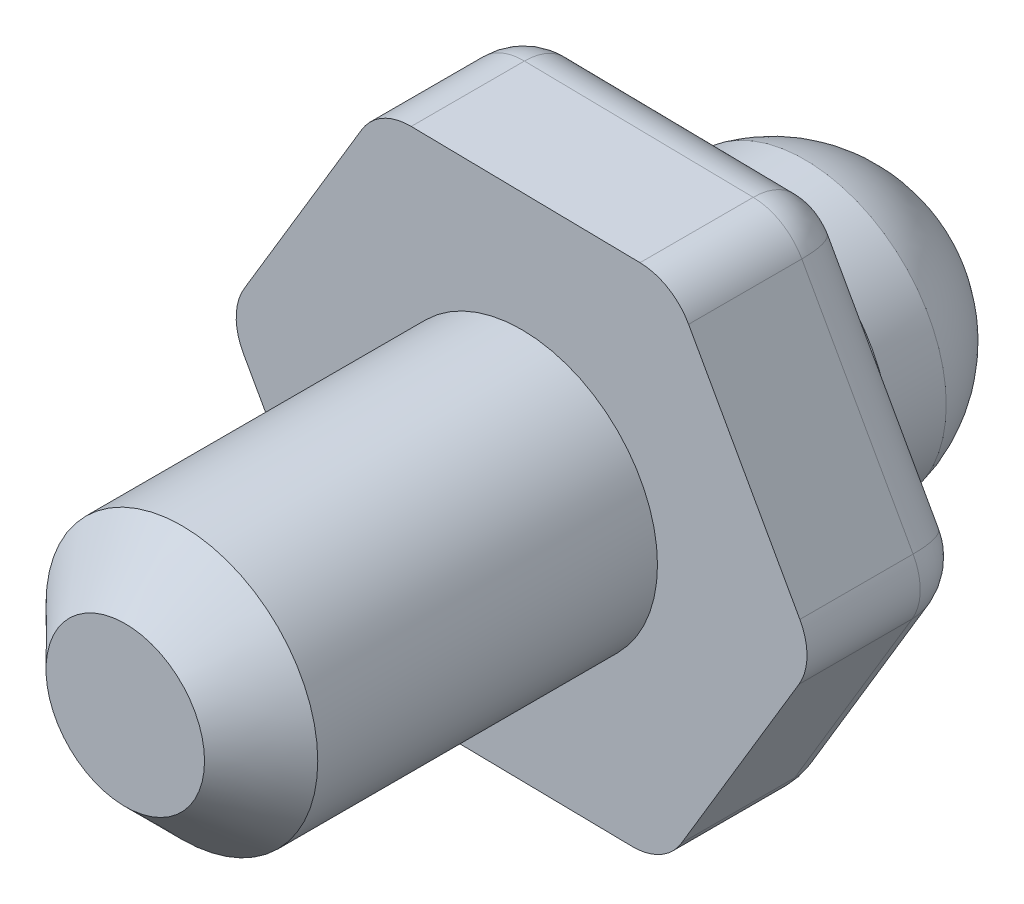
from build123d import *

# Parameters (mm, degrees)
SKETCH1_R         = 3.048
EXTRUDE1_DEPTH    = 8.89
CHAMFER1_SIZE     = 1.27
EXTRUDE2_DEPTH    = 3.81
SKETCH3_R         = 2.029785207
EXTRUDE3_DEPTH    = 1.27
SKETCH4_R         = 3.175
EXTRUDE4_DEPTH    = 1.27
DOME1_FACE_RADIUS = 3.175
DOME1_HEIGHT      = 2.54
FILLET1_R         = 1.27


with BuildPart() as part:
    # Sketch1 → Extrude1 (new body)
    with BuildSketch(Plane.XY):
        Circle(SKETCH1_R)
    extrude(amount=EXTRUDE1_DEPTH)

    # Chamfer1
    chamfer1_edges = [part.edges().sort_by_distance(p)[0] for p in [
        (-3.048, 0, 8.89),
    ]]
    chamfer(chamfer1_edges, length=CHAMFER1_SIZE)

    # Sketch2 → Extrude2 (add)
    with BuildSketch(Plane(origin=(0, 0, 0), x_dir=(-1, 0, 0), z_dir=(0, 0, -1))):
        Polygon((6.598292207, 0.104115064), (3.208979813, 5.766346205), (-3.389312394, 5.662231141), (-6.598292207, -0.104115064), (-3.208979813, -5.766346205), (3.389312394, -5.662231141), align=None)
    extrude(amount=EXTRUDE2_DEPTH)

    # Sketch3 → Extrude3 (add)
    with BuildSketch(Plane(origin=(0, 0, -3.81), x_dir=(-1, 0, 0), z_dir=(0, 0, -1))):
        Circle(SKETCH3_R)
    extrude(amount=EXTRUDE3_DEPTH)

    # Sketch4 → Extrude4 (add)
    with BuildSketch(Plane(origin=(0, 0, -5.08), x_dir=(-1, 0, 0), z_dir=(0, 0, -1))):
        Circle(SKETCH4_R)
    extrude(amount=EXTRUDE4_DEPTH)

    # Dome1: a dome of height H over a round flat face of radius A is a cap of a sphere of radius (A * A + H * H) / (2 * H)
    dome1_r = (DOME1_FACE_RADIUS * DOME1_FACE_RADIUS + DOME1_HEIGHT * DOME1_HEIGHT) / (2 * DOME1_HEIGHT)
    dome1_base = Plane((0, 0, -6.35), z_dir=(0, 0, -1))
    with Locations(dome1_base.offset(DOME1_HEIGHT - dome1_r)):
        dome1_ball = Sphere(dome1_r, mode=Mode.PRIVATE)
    add(split(dome1_ball, bisect_by=dome1_base, keep=Keep.TOP, mode=Mode.PRIVATE))

    # Fillet1
    fillet1_edges = [part.edges().sort_by_distance(p)[0] for p in [
        (3.389312394, 5.662231141, -1.905),
        (6.598292207, -0.104115064, -1.905),
        (3.208979813, -5.766346205, -1.905),
        (-4.993802301, -2.779058038, -3.81),
        (-4.90363601, 2.935230635, -3.81),
        (0.090166291, 5.714288673, -3.81),
        (4.993802301, 2.779058038, -3.81),
        (4.90363601, -2.935230635, -3.81),
        (-0.090166291, -5.714288673, -3.81),
        (-3.389312394, -5.662231141, -1.905),
        (-6.598292207, 0.104115064, -1.905),
        (-3.208979813, 5.766346205, -1.905),
    ]]
    fillet(fillet1_edges, radius=FILLET1_R)


solid = part.part
